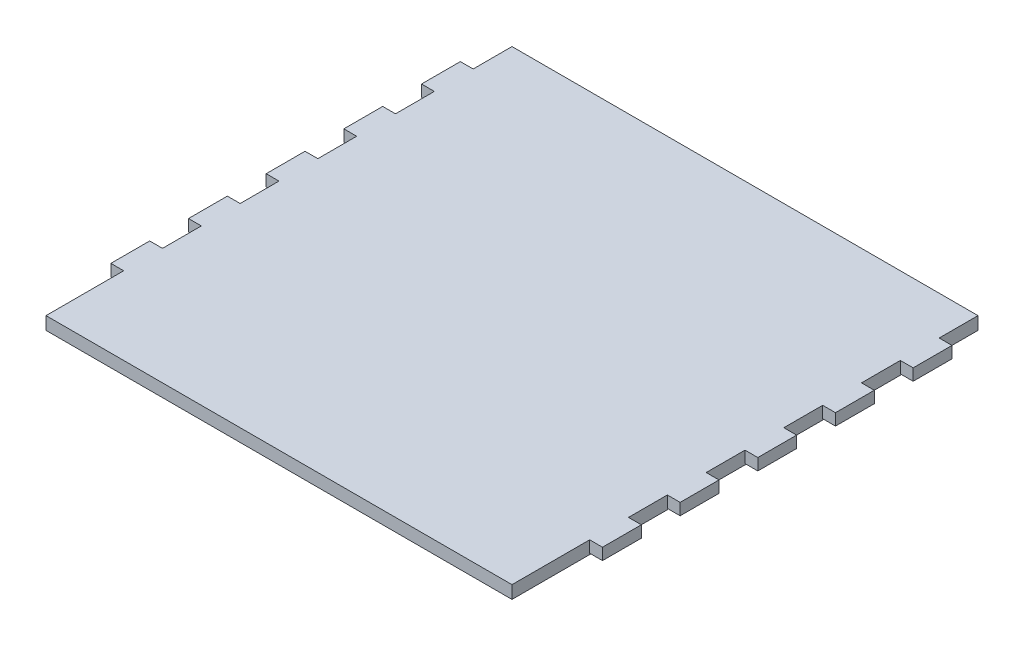
from build123d import *

# Parameters (mm, degrees)
SKETCH1_W               = 120
SKETCH1_H               = 120
BOSS_EXTRUDE1_DEPTH     = 3.3
SKETCH2_W               = 3.3
SKETCH2_H               = 10
BOSS_EXTRUDE2_DEPTH     = 3
LPATTERN1_COUNT         = 5
LPATTERN1_PITCH         = 20
MIRROR1_COPY_1_SKETCH_W = 3.3
MIRROR1_COPY_1_SKETCH_H = 10
MIRROR1_COPY_1_DEPTH    = 3
MIRROR1_COPY_2_SKETCH_W = 3.3
MIRROR1_COPY_2_SKETCH_H = 10
MIRROR1_COPY_2_DEPTH    = 3
MIRROR1_COPY_3_SKETCH_W = 3.3
MIRROR1_COPY_3_SKETCH_H = 10
MIRROR1_COPY_3_DEPTH    = 3
MIRROR1_COPY_4_SKETCH_W = 3.3
MIRROR1_COPY_4_SKETCH_H = 10
MIRROR1_COPY_4_DEPTH    = 3


with BuildPart() as part:
    # Sketch1 → Boss-Extrude1 (new body)
    with BuildSketch(Plane(origin=(0, 0, 0), x_dir=(1, 0, 0), z_dir=(0, 1, 0))):
        Rectangle(SKETCH1_W, SKETCH1_H)
    extrude(amount=BOSS_EXTRUDE1_DEPTH)

    # Sketch2 → Boss-Extrude2 (add)
    with BuildSketch(Plane(origin=(0, 3.3, 0), x_dir=(1, 0, 0), z_dir=(0, 1, 0))):
        with Locations((61.65, 45)):
            Rectangle(SKETCH2_W, SKETCH2_H)
    boss_extrude2 = extrude(amount=-BOSS_EXTRUDE2_DEPTH)

    # LPattern1: Boss-Extrude2 ×5
    with Locations(*[(0, 0, i * LPATTERN1_PITCH) for i in range(1, LPATTERN1_COUNT)]):
        add(boss_extrude2)

    # Mirror1: Boss-Extrude2 across plane
    add(boss_extrude2.mirror(Plane(origin=(0, 0, 0), x_dir=(0, 0, 1), z_dir=(1, 0, 0))))

    # Mirror1 copy 1 sketch → Mirror1 copy 1 (add)
    with BuildSketch(Plane(origin=(0, 3.3, 20), x_dir=(-1, 0, 0), z_dir=(0, 1, 0))):
        with Locations((61.65, -45)):
            Rectangle(MIRROR1_COPY_1_SKETCH_W, MIRROR1_COPY_1_SKETCH_H)
    extrude(amount=-MIRROR1_COPY_1_DEPTH)

    # Mirror1 copy 2 sketch → Mirror1 copy 2 (add)
    with BuildSketch(Plane(origin=(0, 3.3, 40), x_dir=(-1, 0, 0), z_dir=(0, 1, 0))):
        with Locations((61.65, -45)):
            Rectangle(MIRROR1_COPY_2_SKETCH_W, MIRROR1_COPY_2_SKETCH_H)
    extrude(amount=-MIRROR1_COPY_2_DEPTH)

    # Mirror1 copy 3 sketch → Mirror1 copy 3 (add)
    with BuildSketch(Plane(origin=(0, 3.3, 60), x_dir=(-1, 0, 0), z_dir=(0, 1, 0))):
        with Locations((61.65, -45)):
            Rectangle(MIRROR1_COPY_3_SKETCH_W, MIRROR1_COPY_3_SKETCH_H)
    extrude(amount=-MIRROR1_COPY_3_DEPTH)

    # Mirror1 copy 4 sketch → Mirror1 copy 4 (add)
    with BuildSketch(Plane(origin=(0, 3.3, 80), x_dir=(-1, 0, 0), z_dir=(0, 1, 0))):
        with Locations((61.65, -45)):
            Rectangle(MIRROR1_COPY_4_SKETCH_W, MIRROR1_COPY_4_SKETCH_H)
    extrude(amount=-MIRROR1_COPY_4_DEPTH)


solid = part.part
